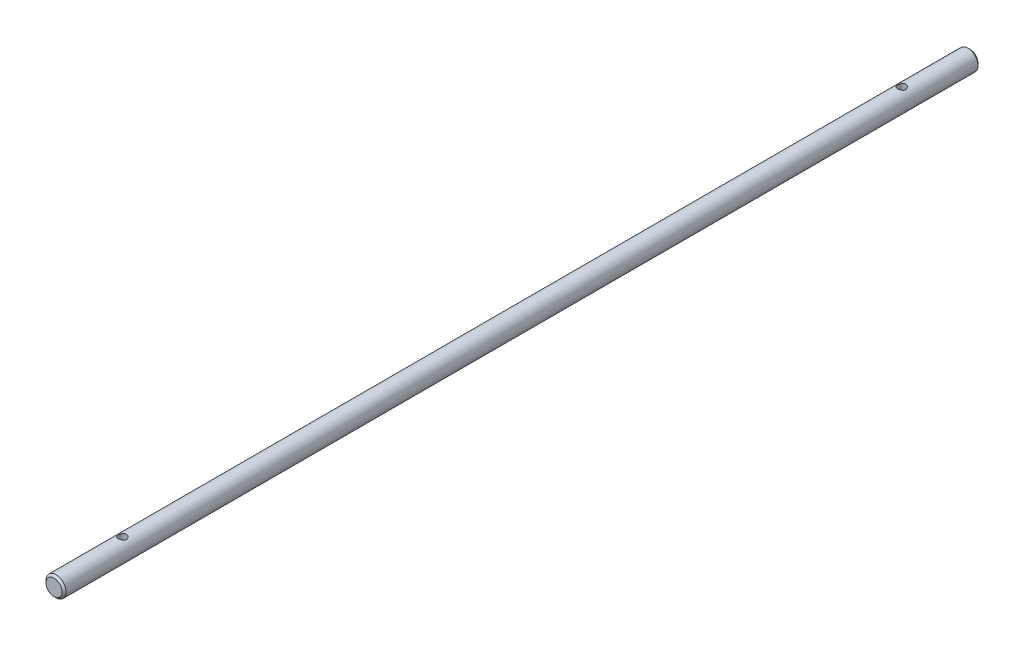
from build123d import *

# Parameters (mm, degrees)
ESQUISSE1_R             = 2.5
BASE_EXTRUSION_DEPTH    = 228
CHANFREIN1_SIZE         = 0.5
ESQUISSE2_R             = 1
ENL_V_MAT_EXTRU_1_DEPTH = 50


with BuildPart() as part:
    # Esquisse1 → Base-Extrusion (new body)
    with BuildSketch(Plane.XY):
        Circle(ESQUISSE1_R)
    extrude(amount=BASE_EXTRUSION_DEPTH)

    # Chanfrein1
    chanfrein1_edges = [part.edges().sort_by_distance(p)[0] for p in [
        (-2.5, 0, 0),
        (-2.5, 0, 228),
    ]]
    chamfer(chanfrein1_edges, length=CHANFREIN1_SIZE)

    # Esquisse2 → Enlèv. mat.-Extru.1 (cut, symmetric)
    with BuildSketch(Plane(origin=(0, 0, 0), x_dir=(1, 0, 0), z_dir=(0, 1, 0))):
        with Locations((0, -17)):
            Circle(ESQUISSE2_R)
        with Locations((0, -211)):
            Circle(ESQUISSE2_R)
    extrude(amount=ENL_V_MAT_EXTRU_1_DEPTH, both=True, mode=Mode.SUBTRACT)


solid = part.part
